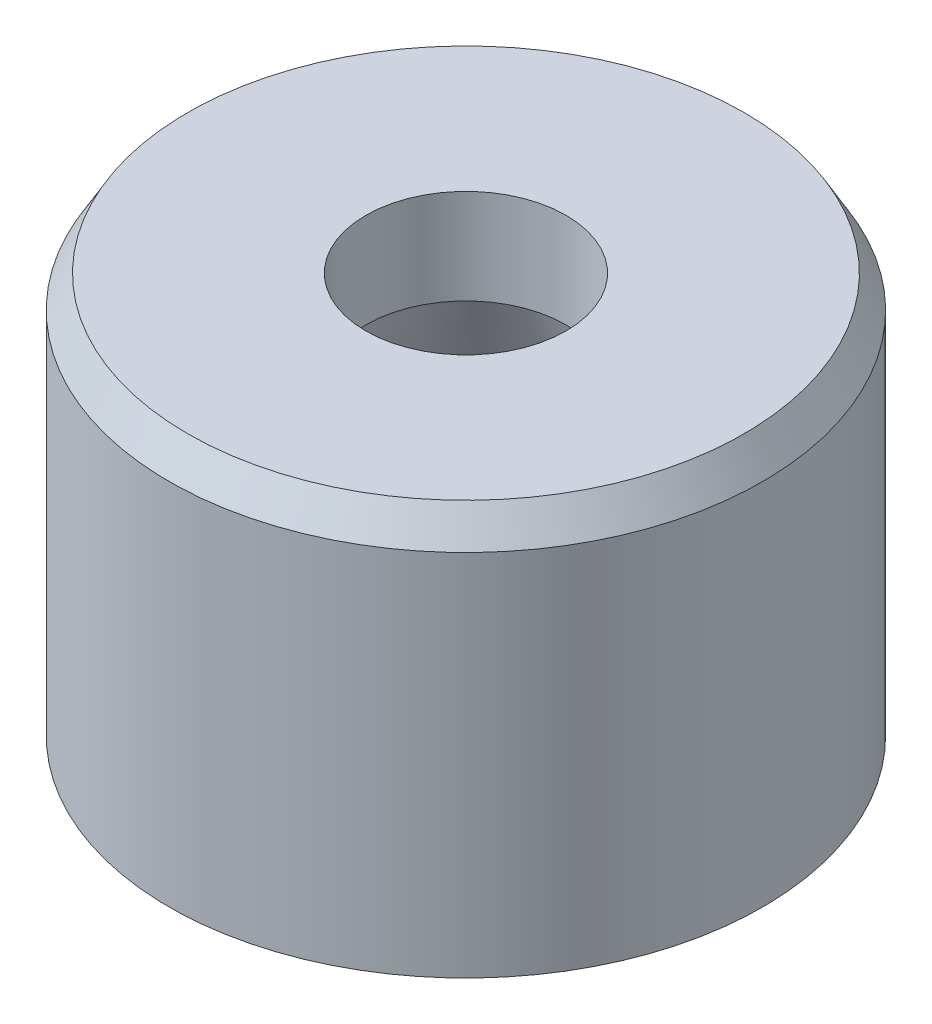
from build123d import *


with BuildPart() as part:
    # Sketch1 → Revolve1 (revolve)
    with BuildSketch(Plane.XY):
        Polygon((7.5, 10.8), (2.7, 10.8), (2.7, 8.242432258), (5.7, 0), (8, 0), (8, 9.933974596), align=None)
    revolve(axis=Axis((0, 10.8, 0), (0, -1, 0)))


solid = part.part
